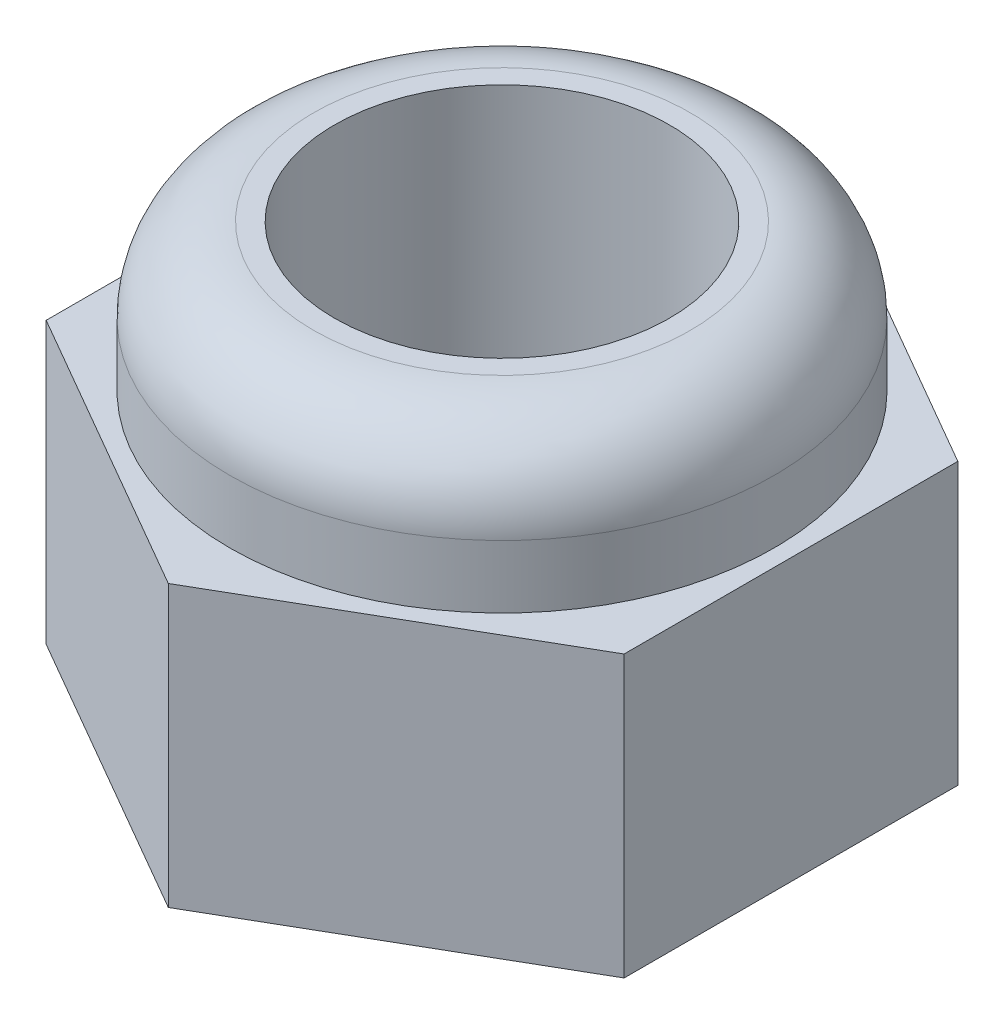
from build123d import *

# Parameters (mm, degrees)
SKETCH1_R           = 2
BOSS_EXTRUDE1_DEPTH = 3.35
SKETCH2_R           = 3.25
SKETCH2_R_2         = 2
BOSS_EXTRUDE2_DEPTH = 1.75
FILLET1_R           = 1


with BuildPart() as part:
    # Sketch1 → Boss-Extrude1 (new body)
    with BuildSketch(Plane(origin=(0, 0, 0), x_dir=(1, 0, 0), z_dir=(0, 1, 0))):
        Polygon((0, 3.983716857), (-3.45, 1.991858429), (-3.45, -1.991858429), (0, -3.983716857), (3.45, -1.991858429), (3.45, 1.991858429), align=None)
        Circle(SKETCH1_R, mode=Mode.SUBTRACT)
    extrude(amount=BOSS_EXTRUDE1_DEPTH)

    # Sketch2 → Boss-Extrude2 (add)
    with BuildSketch(Plane(origin=(0, 3.35, 0), x_dir=(1, 0, 0), z_dir=(0, 1, 0))):
        Circle(SKETCH2_R)
        Circle(SKETCH2_R_2, mode=Mode.SUBTRACT)
    extrude(amount=BOSS_EXTRUDE2_DEPTH)

    # Fillet1
    fillet1_edges = [part.edges().sort_by_distance(p)[0] for p in [
        (-3.25, 5.1, 0),
    ]]
    fillet(fillet1_edges, radius=FILLET1_R)


solid = part.part
